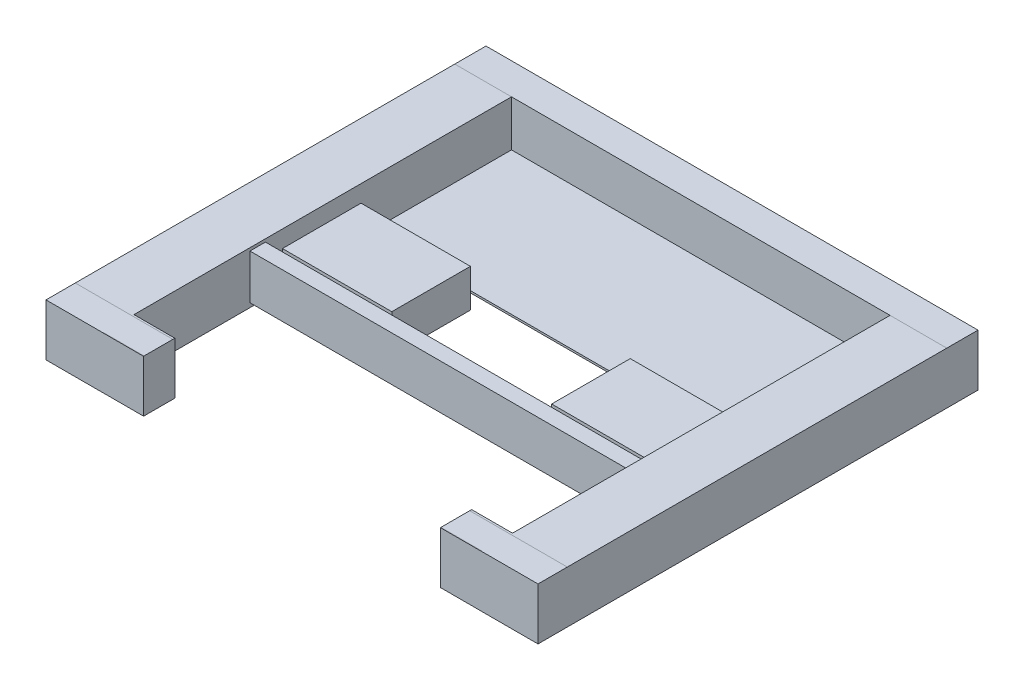
from build123d import *

# Parameters (mm, degrees)
BOSS_EXTRUDE1_DEPTH = 92.28812
BOSS_EXTRUDE2_DEPTH = 66.46188
BOSS_EXTRUDE3_DEPTH = 307.975
BOSS_EXTRUDE4_DEPTH = 177.926
SKETCH6_W           = 25.148038513
SKETCH6_H           = 72.870812273
BOSS_EXTRUDE5_DEPTH = 307.975


with BuildPart() as part:
    # Sketch1 → Boss-Extrude1 (new body)
    with BuildSketch(Plane.ZY.offset(470.597286824)):
        Polygon((375.982707359, 100.269590084), (375.982707359, 15.687590084), (347.407707359, 15.687590084), (-308.166292641, 15.433590084), (-339.916292641, 15.433590084), (-339.916292641, 100.015590084), (-289.116292641, 100.015590084), (328.357707359, 100.269590084), align=None)
    extrude(amount=-BOSS_EXTRUDE1_DEPTH)

    # Sketch2 → Boss-Extrude2 (add)
    with BuildSketch(Plane(origin=(-378.309166646, 0, 0), x_dir=(0, 0, -1), z_dir=(1, 0, 0))):
        Polygon((-375.220707359, 18.862590084), (-344.232707359, 18.862590084), (-344.232707359, 15.687590084), (-325.182707359, 15.687590084), (-325.182707359, 97.094590084), (-375.220707359, 97.094590084), align=None)
        Polygon((-375.220707359, 100.269590084), (-375.220707359, 97.094590084), (-325.182707359, 97.094590084), (-325.182707359, 100.268284038), (-328.357707359, 100.269590084), align=None)
        with BuildLine():
            ThreePointArc((-375.982707359, 96.332590084), (-375.759522726, 96.871405452), (-375.220707359, 97.094590084))
            Line((-375.220707359, 97.094590084), (-375.220707359, 100.269590084))
            ThreePointArc((-375.220707359, 100.269590084), (-375.60352134, 100.250934436), (-375.982707359, 100.195144291))
            Line((-375.982707359, 100.195144291), (-375.982707359, 96.332590084))
        make_face()
        with BuildLine():
            ThreePointArc((-375.982707359, 19.624590084), (-375.759522726, 19.085774717), (-375.220707359, 18.862590084))
            Line((-375.220707359, 18.862590084), (-375.220707359, 97.094590084))
            ThreePointArc((-375.220707359, 97.094590084), (-375.759522726, 96.871405452), (-375.982707359, 96.332590084))
            Line((-375.982707359, 96.332590084), (-375.982707359, 19.624590084))
        make_face()
        Polygon((-344.232707359, 15.687590084), (-344.232707359, 18.862590084), (-375.220707359, 18.862590084), (-375.220707359, 15.687590084), (-347.407707359, 15.687590084), align=None)
        with BuildLine():
            Line((-375.220707359, 15.687590084), (-375.220707359, 18.862590084))
            ThreePointArc((-375.220707359, 18.862590084), (-375.759522726, 19.085774717), (-375.982707359, 19.624590084))
            Line((-375.982707359, 19.624590084), (-375.982707359, 15.762035878))
            ThreePointArc((-375.982707359, 15.762035878), (-375.60352134, 15.706245733), (-375.220707359, 15.687590084))
        make_face()
    extrude(amount=BOSS_EXTRUDE2_DEPTH)

    # Sketch3 → Boss-Extrude3 (add)
    with BuildSketch(Plane(origin=(-378.309166646, 0, 0), x_dir=(0, 0, -1), z_dir=(1, 0, 0))):
        Polygon((289.116292641, 100.015590084), (289.116292641, 25.212590084), (57.341292641, 25.212590084), (57.341292641, 22.037590084), (289.116292641, 22.037590084), (289.116292641, 15.440970945), (308.166292641, 15.433590084), (339.916292641, 15.433590084), (339.916292641, 100.015590084), align=None)
    extrude(amount=BOSS_EXTRUDE3_DEPTH)

    # Sketch4 → Boss-Extrude4 (add)
    with BuildSketch(Plane(origin=(-378.309166646, 0, 0), x_dir=(0, 0, -1), z_dir=(1, 0, 0))):
        with BuildLine():
            ThreePointArc((44.31439752, 41.659090084), (35.270733675, 63.492426094), (13.437397726, 72.536090084))
            ThreePointArc((13.437397726, 72.536090084), (-5.359329042, 66.155461235), (-16.387494219, 49.65064574))
            ThreePointArc((-16.387494219, 49.65064574), (-15.318667207, 30.412852027), (-3.052669821, 15.554170853))
            Line((-3.052669821, 15.554170853), (29.907231382, 15.541400647))
            ThreePointArc((29.907231382, 15.541400647), (38.295788177, 23.343808407), (43.262289258, 33.667534429))
            ThreePointArc((43.262289258, 33.667534429), (44.050240504, 37.628832847), (44.31439752, 41.659090084))
        make_face()
        with BuildLine():
            ThreePointArc((-22.8539205, 49.65064574), (-33.882085595, 66.155461173), (-52.678812238, 72.536090084))
            ThreePointArc((-52.678812238, 72.536090084), (-74.512148435, 63.492426054), (-83.555812238, 41.659089763))
            ThreePointArc((-83.555812238, 41.659089763), (-83.291655202, 37.628832688), (-82.503703977, 33.667534429))
            ThreePointArc((-82.503703977, 33.667534429), (-77.55849945, 23.372748372), (-69.209387458, 15.579803056))
            Line((-69.209387458, 15.579803056), (-36.168450647, 15.567001453))
            ThreePointArc((-36.168450647, 15.567001453), (-23.918377136, 30.424033264), (-22.8539205, 49.65064574))
        make_face()
        with BuildLine():
            Line((13.437397726, 72.536090084), (-52.678812238, 72.536090084))
            ThreePointArc((-52.678812238, 72.536090084), (-33.882085595, 66.155461173), (-22.8539205, 49.65064574))
            ThreePointArc((-22.8539205, 49.65064574), (-23.918377136, 30.424033264), (-36.168450647, 15.567001453))
            Line((-36.168450647, 15.567001453), (-3.052669821, 15.554170853))
            ThreePointArc((-3.052669821, 15.554170853), (-15.318667207, 30.412852027), (-16.387494219, 49.65064574))
            ThreePointArc((-16.387494219, 49.65064574), (-5.359329042, 66.155461235), (13.437397726, 72.536090084))
        make_face()
        with BuildLine():
            ThreePointArc((-52.678812238, 10.782090084), (-44.083938524, 12.002433583), (-36.168450647, 15.567001453))
            Line((-36.168450647, 15.567001453), (-69.209387458, 15.579803056))
            ThreePointArc((-69.209387458, 15.579803056), (-61.285175681, 12.005765865), (-52.678812238, 10.782090084))
        make_face()
        with BuildLine():
            Line((-3.052669821, 15.554170853), (-36.168450647, 15.567001453))
            ThreePointArc((-36.168450647, 15.567001453), (-44.083938524, 12.002433583), (-52.678812238, 10.782090084))
            Line((-52.678812238, 10.782090084), (13.437397518, 10.782090084))
            ThreePointArc((13.437397518, 10.782090084), (4.854054992, 11.999094129), (-3.052669821, 15.554170853))
        make_face()
        with BuildLine():
            Line((29.907231382, 15.541400647), (-3.052669821, 15.554170853))
            ThreePointArc((-3.052669821, 15.554170853), (4.854054992, 11.999094129), (13.437397518, 10.782090084))
            ThreePointArc((13.437397518, 10.782090084), (22.009247734, 11.995770768), (29.907231382, 15.541400647))
        make_face()
        with BuildLine():
            Line((44.31439752, 10.782090084), (44.31439752, 15.535818637))
            Line((44.31439752, 15.535818637), (29.907231382, 15.541400647))
            ThreePointArc((29.907231382, 15.541400647), (22.009247734, 11.995770768), (13.437397518, 10.782090084))
            Line((13.437397518, 10.782090084), (44.31439752, 10.782090084))
        make_face()
        with BuildLine():
            Line((-69.209387458, 15.579803056), (-83.555812238, 15.585361532))
            Line((-83.555812238, 15.585361532), (-83.555812238, 10.782090084))
            Line((-83.555812238, 10.782090084), (-52.678812238, 10.782090084))
            ThreePointArc((-52.678812238, 10.782090084), (-61.285175681, 12.005765865), (-69.209387458, 15.579803056))
        make_face()
        with BuildLine():
            ThreePointArc((-82.503703977, 33.667534429), (-83.291655202, 37.628832688), (-83.555812238, 41.659089763))
            Line((-83.555812238, 41.659089763), (-83.555812238, 15.585361532))
            Line((-83.555812238, 15.585361532), (-69.209387458, 15.579803056))
            ThreePointArc((-69.209387458, 15.579803056), (-77.55849945, 23.372748372), (-82.503703977, 33.667534429))
        make_face()
        with BuildLine():
            Line((-52.678812238, 72.536090084), (-83.555812238, 72.536090084))
            Line((-83.555812238, 72.536090084), (-83.555812238, 41.659089763))
            ThreePointArc((-83.555812238, 41.659089763), (-74.512148435, 63.492426054), (-52.678812238, 72.536090084))
        make_face()
        with BuildLine():
            Line((44.31439752, 72.536090084), (13.437397726, 72.536090084))
            ThreePointArc((13.437397726, 72.536090084), (35.270733675, 63.492426094), (44.31439752, 41.659090084))
            Line((44.31439752, 41.659090084), (44.31439752, 72.536090084))
        make_face()
        with BuildLine():
            Line((44.31439752, 15.535818637), (44.31439752, 41.659090084))
            ThreePointArc((44.31439752, 41.659090084), (44.050240504, 37.628832847), (43.262289258, 33.667534429))
            ThreePointArc((43.262289258, 33.667534429), (38.295788177, 23.343808407), (29.907231382, 15.541400647))
            Line((29.907231382, 15.541400647), (44.31439752, 15.535818637))
        make_face()
    extrude(amount=BOSS_EXTRUDE4_DEPTH)

    # Sketch6 → Boss-Extrude5 (add)
    with BuildSketch(Plane(origin=(-378.309166646, 0, 0), x_dir=(0, 0, -1), z_dir=(1, 0, 0))):
        with Locations((-123.855467844, 59.050323619)):
            Rectangle(SKETCH6_W, SKETCH6_H)
    extrude(amount=BOSS_EXTRUDE5_DEPTH)

    # Mirror1: part across plane


with BuildPart() as part_1:
    add(part.part)
    add(part.part.mirror(Plane(origin=(-70.334166646, 0, 0), x_dir=(0, 0, 1), z_dir=(1, 0, 0))))


solid = part_1.part
